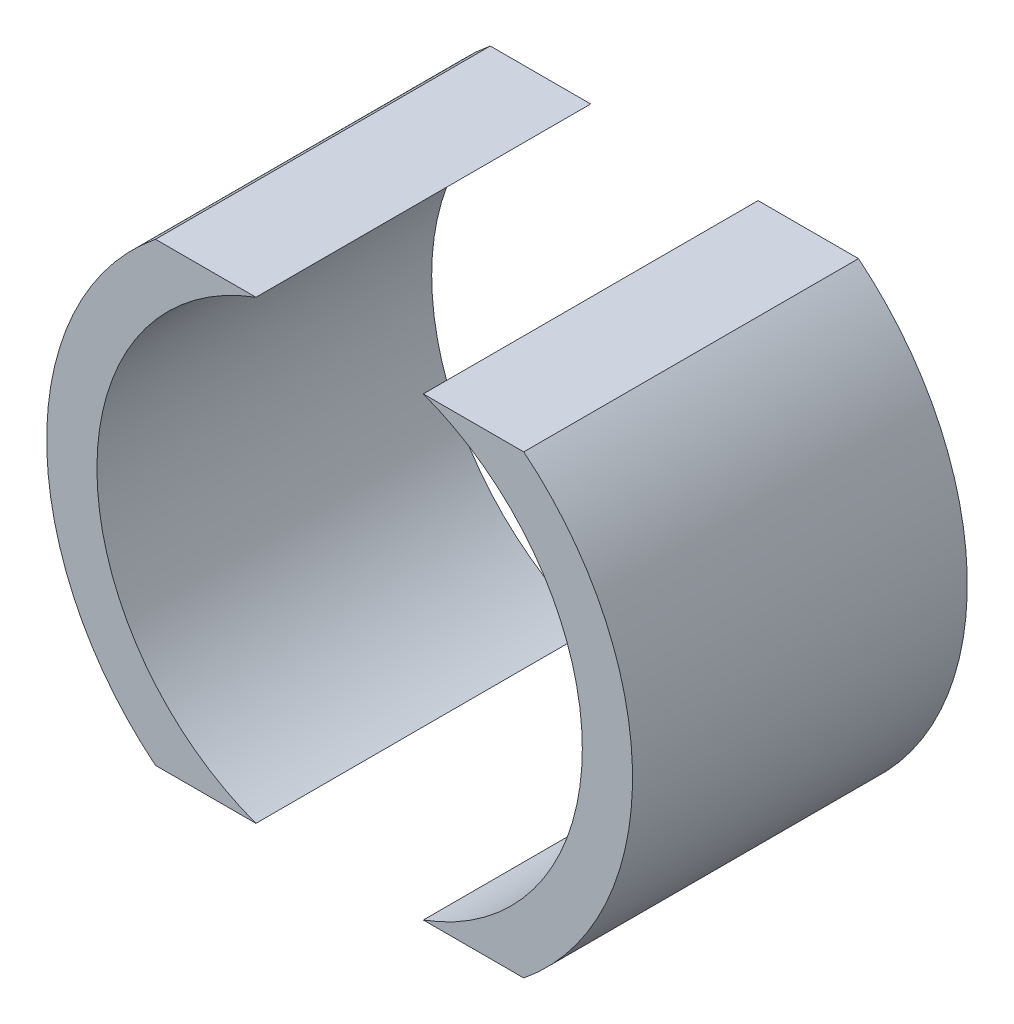
from build123d import *

# Parameters (mm, degrees)
BOSS_EXTRUDE3_DEPTH   = 20
BOSS_EXTRUDE3_2_DEPTH = 20


with BuildPart() as part:
    # Sketch1 → Boss-Extrude3 (new body)
    with BuildSketch(Plane.XY):
        with BuildLine():
            Line((-5, 13.610657589), (-11, 13.610657589))
            ThreePointArc((-11, 13.610657589), (-17.5, 0), (-11, -13.610657589))
            Line((-11, -13.610657589), (-5, -13.610657589))
            ThreePointArc((-5, -13.610657589), (-14.5, 0), (-5, 13.610657589))
        make_face()
    extrude(amount=BOSS_EXTRUDE3_DEPTH)


with BuildPart() as body_2:
    # Sketch1 → Boss-Extrude3 2 (new body)
    with BuildSketch(Plane.XY):
        with BuildLine():
            Line((5, 13.610657589), (11, 13.610657589))
            ThreePointArc((11, 13.610657589), (17.5, 0), (11, -13.610657589))
            Line((11, -13.610657589), (5, -13.610657589))
            ThreePointArc((5, -13.610657589), (14.5, 0), (5, 13.610657589))
        make_face()
    extrude(amount=BOSS_EXTRUDE3_2_DEPTH)


solid = Compound([part.part, body_2.part])
